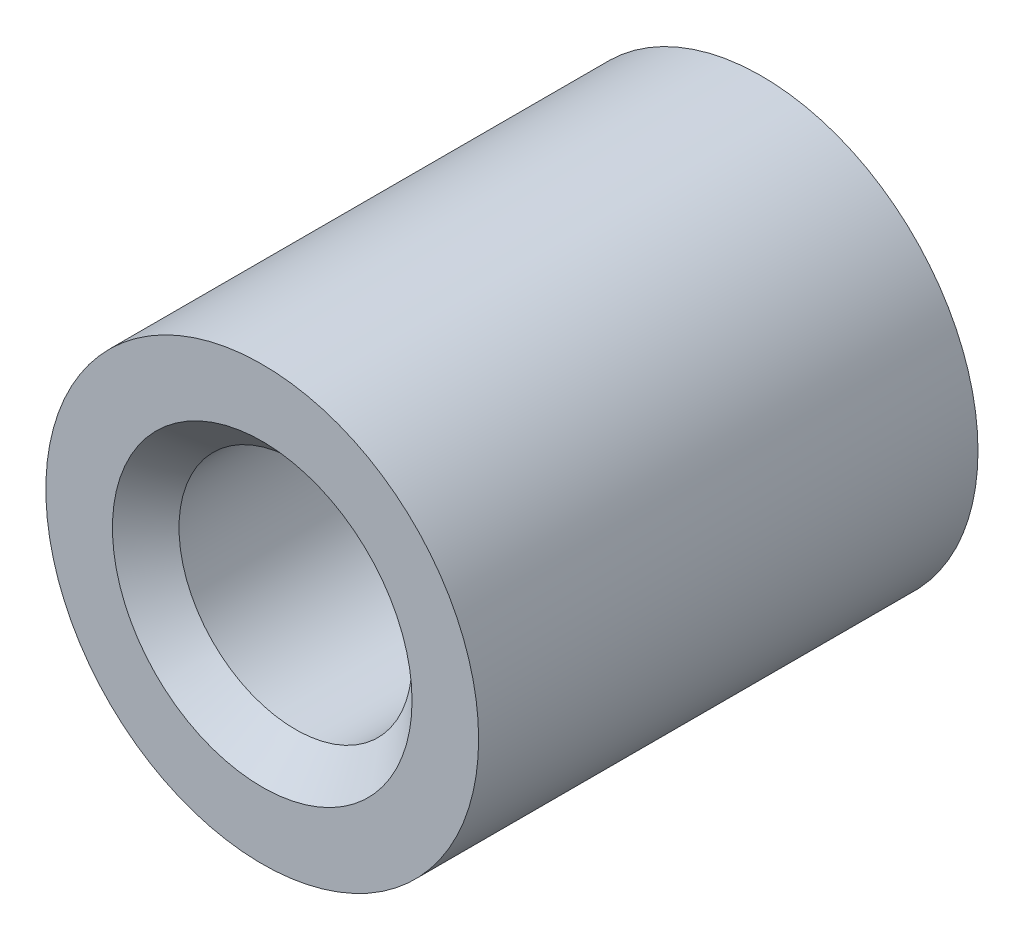
from build123d import *

# Parameters (mm, degrees)
SKETCH2_R           = 6.5
SKETCH2_R_2         = 3.5
BOSS_EXTRUDE1_DEPTH = 15
CHAMFER1_SIZE       = 1


with BuildPart() as part:
    # Sketch2 → Boss-Extrude1 (new body)
    with BuildSketch(Plane.XY):
        Circle(SKETCH2_R)
        Circle(SKETCH2_R_2, mode=Mode.SUBTRACT)
    extrude(amount=BOSS_EXTRUDE1_DEPTH)

    # Chamfer1
    chamfer1_edges = [part.edges().sort_by_distance(p)[0] for p in [
        (-3.5, 0, 0),
        (-3.5, 0, 15),
    ]]
    chamfer(chamfer1_edges, length=CHAMFER1_SIZE)


solid = part.part
